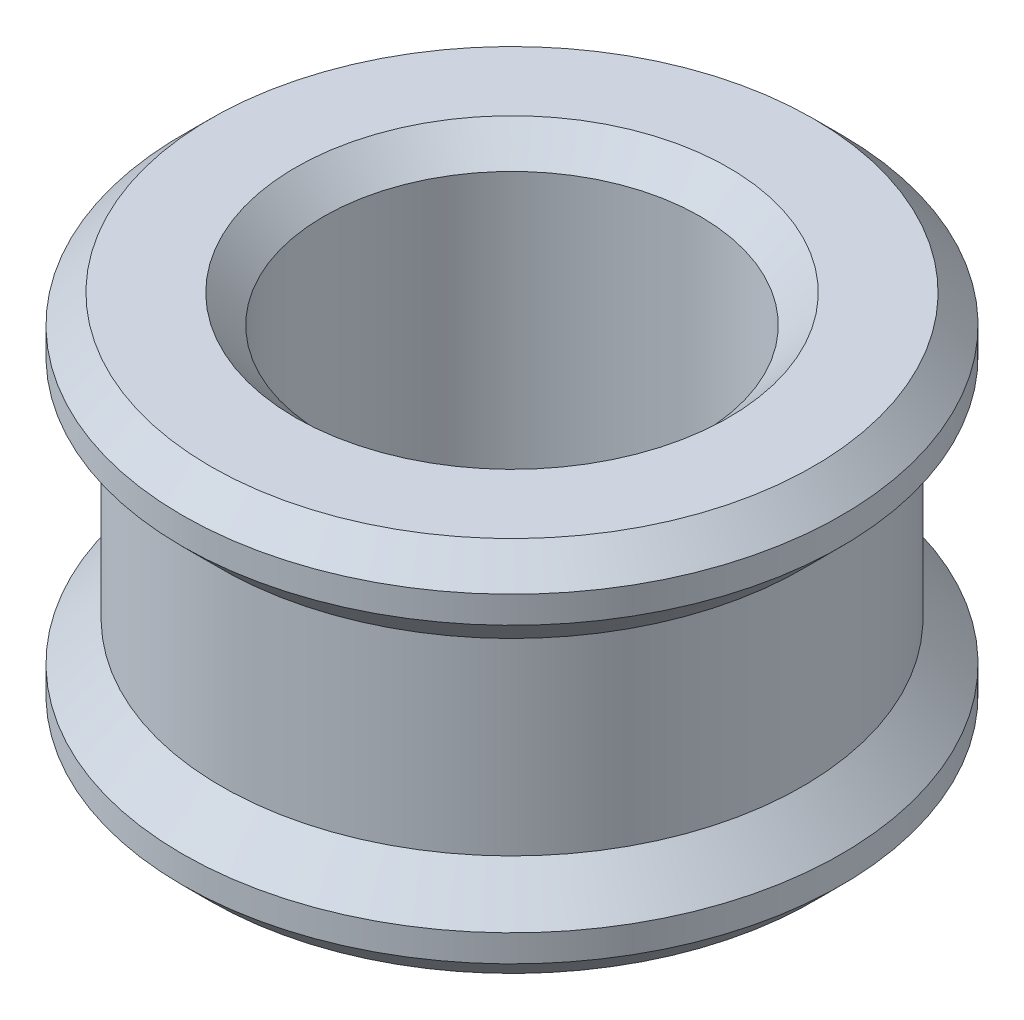
from build123d import *

# Parameters (mm, degrees)
CHAMFER1_SIZE = 0.3


with BuildPart() as part:
    # Sketch2 → Revolve1 (revolve)
    with BuildSketch(Plane.XY):
        Polygon((2, 0), (2, 4), (3.5, 4), (3.5, 3.414213562), (3.085786438, 3), (3.085786438, 1), (3.5, 0.585786438), (3.5, 0), align=None)
    revolve(axis=Axis((0, 0, 0), (0, 1, 0)))

    # Chamfer1
    chamfer1_edges = [part.edges().sort_by_distance(p)[0] for p in [
        (-2, 0, 0),
        (-3.5, 0, 0),
        (-3.5, 4, 0),
        (-2, 4, 0),
    ]]
    chamfer(chamfer1_edges, length=CHAMFER1_SIZE)


solid = part.part
